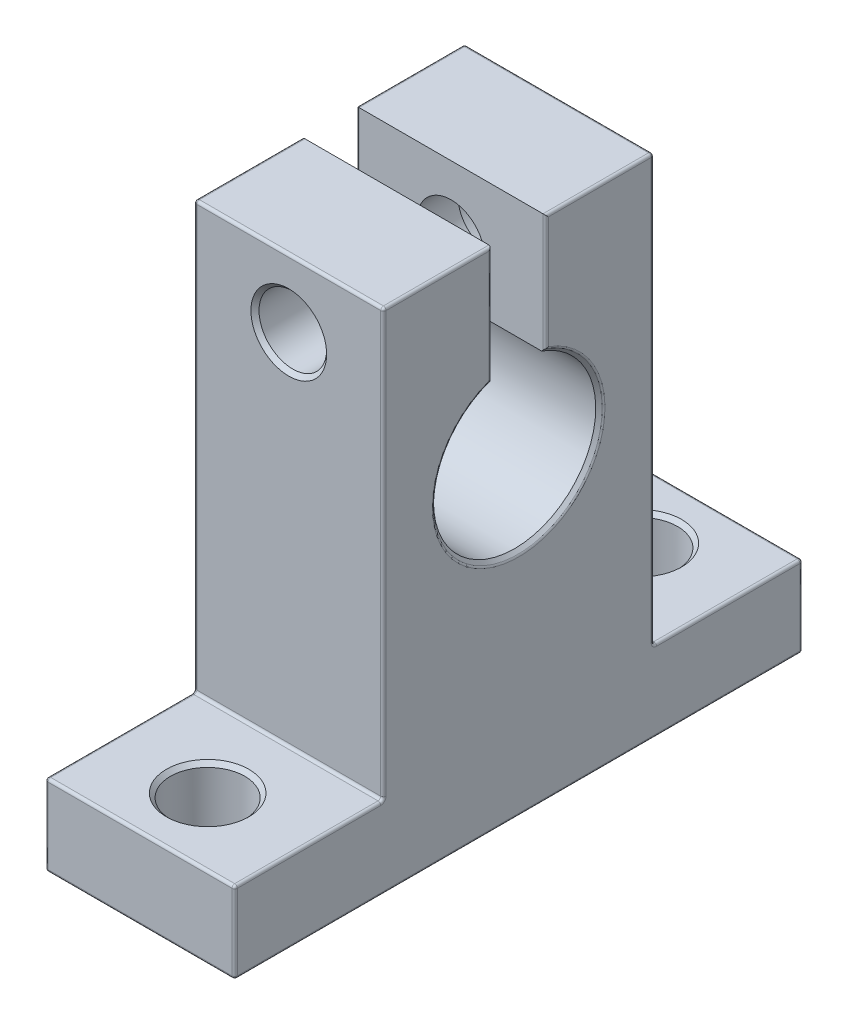
from build123d import *

# Parameters (mm, degrees)
BOSS_EXTRUDE1_DEPTH = 7
SKETCH2_R           = 2.75
CUT_EXTRUDE1_DEPTH  = 7
SKETCH3_R           = 2.5
CUT_EXTRUDE2_DEPTH  = 32
SKETCH4_R           = 4
CUT_EXTRUDE3_DEPTH  = 5
CHAMFER_1_SIZE      = 0.3
FILLET_1_R          = 0.2


with BuildPart() as part:
    # Sketch1 → Boss-Extrude1 (new body, symmetric)
    with BuildSketch(Plane(origin=(0, 0, 0), x_dir=(0, 0, -1), z_dir=(1, 0, 0))):
        with BuildLine():
            Line((-21, 0), (21, 0))
            Line((21, 0), (21, 6))
            Line((21, 6), (10, 6))
            Line((10, 6), (10, 37.5))
            Line((10, 37.5), (2, 37.5))
            Line((2, 37.5), (2, 28.656854249))
            ThreePointArc((2, 28.656854249), (0, 17), (-2, 28.656854249))
            Line((-2, 28.656854249), (-2, 37.5))
            Line((-2, 37.5), (-10, 37.5))
            Line((-10, 37.5), (-10, 6))
            Line((-10, 6), (-21, 6))
            Line((-21, 6), (-21, 0))
        make_face()
    extrude(amount=BOSS_EXTRUDE1_DEPTH, both=True)

    # Sketch2 → Cut-Extrude1 (cut, through all)
    with BuildSketch(Plane(origin=(0, 6, 0), x_dir=(1, 0, 0), z_dir=(0, 1, 0))):
        with Locations(Location((0, 16, 0), (0, 0, 270))):  # turned: the seam where the file's is
            Circle(SKETCH2_R)
        with Locations(Location((0, -16, 0), (0, 0, 270))):  # turned: the seam where the file's is
            Circle(SKETCH2_R)
    extrude(amount=-CUT_EXTRUDE1_DEPTH, mode=Mode.SUBTRACT)

    # Sketch3 → Cut-Extrude2 (cut, through all)
    with BuildSketch(Plane(origin=(0, 0, -10), x_dir=(-1, 0, 0), z_dir=(0, 0, -1))):
        with Locations(Location((0, 32.5, 0), (0, 0, 90))):  # turned: the seam where the file's is
            Circle(SKETCH3_R)
    extrude(amount=-CUT_EXTRUDE2_DEPTH, mode=Mode.SUBTRACT)

    # Sketch4 → Cut-Extrude3 (cut)
    with BuildSketch(Plane(origin=(0, 0, -10), x_dir=(-1, 0, 0), z_dir=(0, 0, -1))):
        with Locations((0, 32.5)):
            Circle(SKETCH4_R)
    extrude(amount=-CUT_EXTRUDE3_DEPTH, mode=Mode.SUBTRACT)

    # Фаска1
    chamfer_1_edges = [part.edges().sort_by_distance(p)[0] for p in [
        (7, 17, 0),
        (0, 0, -18.75),
        (0, 6, -18.75),
        (0, 0, 13.25),
        (0, 6, 13.25),
        (0, 30, 10),
        (4, 32.5, -10),
    ]]
    chamfer(chamfer_1_edges, length=CHAMFER_1_SIZE)

    # Скругление1
    fillet_1_edges = [part.edges().sort_by_distance(p)[0] for p in [
        (-7, 0, 0),
        (-7, 3, -21),
        (-7, 6, -15.5),
        (-7, 21.75, -10),
        (-7, 37.5, -6),
        (-7, 33.078427125, -2),
        (-7, 17, 0),
        (-7, 33.078427125, 2),
        (-7, 37.5, 6),
        (-7, 21.75, 10),
        (-7, 6, 15.5),
        (-7, 3, 21),
        (7, 37.5, -6),
        (7, 21.75, -10),
        (7, 6, -15.5),
        (7, 3, -21),
        (7, 0, 0),
        (7, 3, 21),
        (7, 6, 15.5),
        (7, 21.75, 10),
        (7, 37.5, 6),
        (7, 33.237055406, 2),
        (7, 16.7, 0),
        (7, 33.237055406, -2),
        (0, 0, 21),
        (0, 6, 21),
        (0, 6, 10),
        (0, 37.5, 10),
        (0, 0, -21),
        (0, 6, -21),
        (0, 6, -10),
        (0, 37.5, -10),
    ]]
    fillet(fillet_1_edges, radius=FILLET_1_R)


solid = part.part
